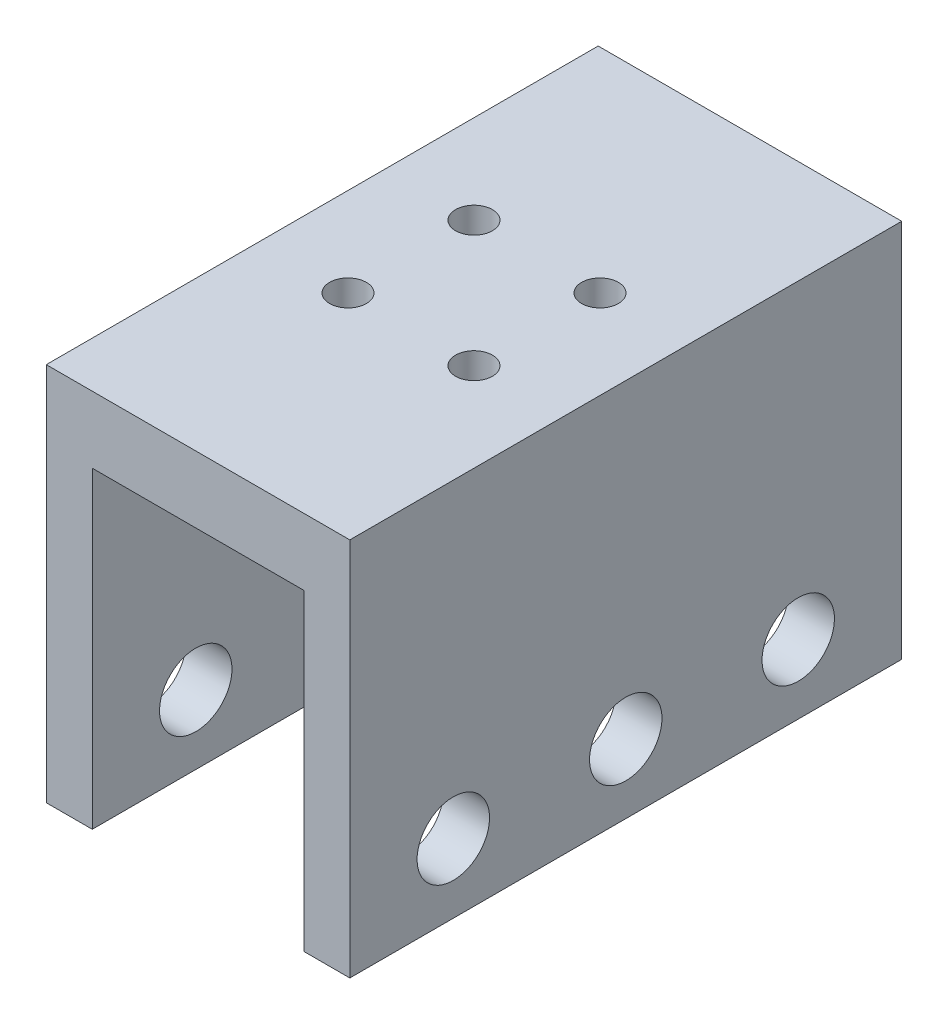
from build123d import *

# Parameters (mm, degrees)
EXTRUDE_1_DEPTH     = 24
SKETCH_2_R          = 1.6
CUT_EXTRUDE_1_DEPTH = 6.8
SKETCH_3_R          = 3.15
CUT_EXTRUDE_2_DEPTH = 26.4


with BuildPart() as part:
    # 草圖1 → 填料-伸長1 (new body, symmetric)
    with BuildSketch(Plane.XY):
        Polygon((0, 0), (0, 33), (26.4, 33), (26.4, 0), (22.4, 0), (22.4, 27.2), (4, 27.2), (4, 0), align=None)
    extrude(amount=EXTRUDE_1_DEPTH, both=True)

    # 草圖2 → 除料-伸長1 (cut, through all)
    with BuildSketch(Plane.XZ.offset(-27.2)):
        with Locations((7.719922446, 5.480077554)):
            Circle(SKETCH_2_R)
        with Locations((18.680077554, 5.480077554)):
            Circle(SKETCH_2_R)
        with Locations((18.680077554, -5.480077554)):
            Circle(SKETCH_2_R)
        with Locations((7.719922446, -5.480077554)):
            Circle(SKETCH_2_R)
    extrude(amount=-CUT_EXTRUDE_1_DEPTH, mode=Mode.SUBTRACT)

    # 草圖3 → 除料-伸長2 (cut)
    with BuildSketch(Plane(origin=(26.4, 0, 0), x_dir=(0, 0, -1), z_dir=(1, 0, 0))):
        with Locations((0, 6)):
            Circle(SKETCH_3_R)
        with Locations((15, 6)):
            Circle(SKETCH_3_R)
        with Locations((-15, 6)):
            Circle(SKETCH_3_R)
    extrude(amount=-CUT_EXTRUDE_2_DEPTH, mode=Mode.SUBTRACT)


solid = part.part
